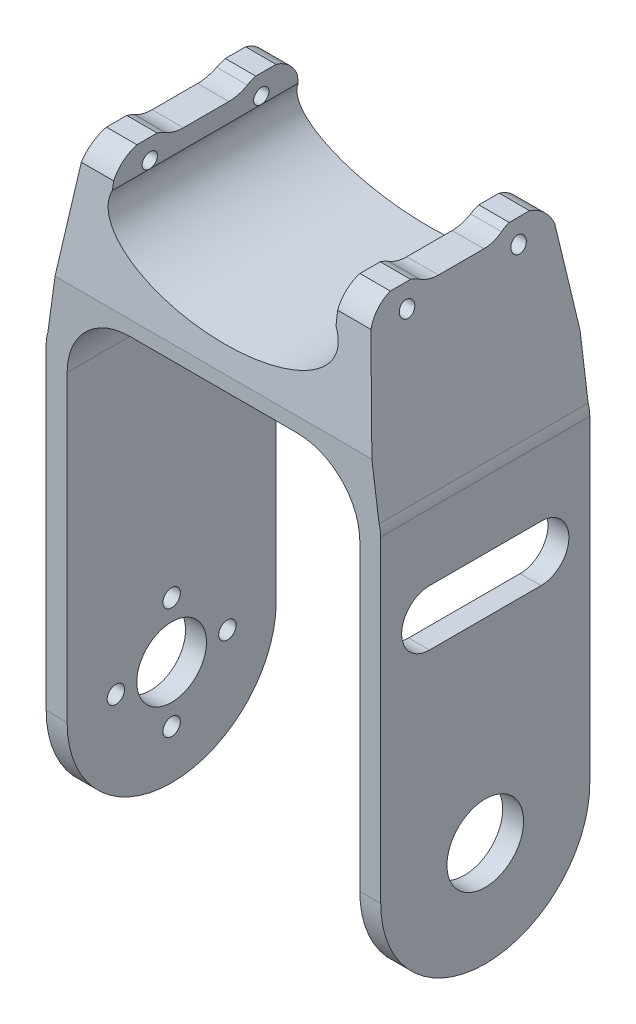
from build123d import *

# Parameters (mm, degrees)
EXTRUDE_1_DEPTH      = 30
SKETCH_3_R           = 5
CUT_EXTRUDE_5_DEPTH  = 56
CUT_EXTRUDE_12_DEPTH = 51
SKETCH_3_4_R         = 1.1
CUT_EXTRUDE_7_DEPTH  = 56
SKETCH_6_R           = 1.25
CUT_EXTRUDE_9_DEPTH  = 22
SKETCH_5_R           = 5.5
CUT_EXTRUDE_13_DEPTH = 10


with BuildPart() as part:
    # Эскиз1 → Бобышка-Вытянуть1 (new body)
    with BuildSketch(Plane.XY):
        with BuildLine():
            ThreePointArc((23.447094189, 8.182803621), (23.388195094, 8.947997617), (23.212885448, 9.69516392))
            Line((23.212885448, 9.69516392), (19.814400159, 34.41595773))
            Line((19.814400159, 34.41595773), (15.447094189, 34.41595773))
            Line((15.447094189, 34.41595773), (15.447094189, 29.601114652))
            add(Edge.make_bspline(
                [(-16.737207413, 30.306768931), (-21.154797026, 21.000420448), (-0.15838441, 20.540065316), (20.838028206, 20.079710184), (15.447094189, 29.601114652)],
                knots=[2.948852751, 2.948852751, 2.948852751, 4.755403061, 4.755403061, 6.56195337, 6.56195337, 6.56195337], degree=2, weights=[1, 0.619041122, 1, 0.619041122, 1]))
            Line((-16.737207413, 30.306768931), (-16.552905811, 34.41595773))
            Line((-16.552905811, 34.41595773), (-20.92021178, 34.41595773))
            Line((-20.92021178, 34.41595773), (-24.31869707, 9.69516392))
            ThreePointArc((-24.31869707, 9.69516392), (-24.494006715, 8.947997617), (-24.552905811, 8.182803621))
            Line((-24.552905811, 8.182803621), (-24.552905811, -52.36689041))
            Line((-24.552905811, -52.36689041), (-21.552905811, -52.36689041))
            Line((-21.552905811, -52.36689041), (-21.552905811, 5.955043958))
            Line((-21.552905811, 5.955043958), (-21.552905811, 6.111376347))
            ThreePointArc((-21.552905811, 6.111376347), (-18.916866841, 12.475337378), (-12.552905811, 15.111376347))
            Line((-12.552905811, 15.111376347), (11.447094189, 15.111376347))
            ThreePointArc((11.447094189, 15.111376347), (17.81105522, 12.475337378), (20.447094189, 6.111376347))
            Line((20.447094189, 6.111376347), (20.447094189, 5.955043958))
            Line((20.447094189, 5.955043958), (20.447094189, -52.36689041))
            Line((20.447094189, -52.36689041), (23.447094189, -52.36689041))
            Line((23.447094189, -52.36689041), (23.447094189, 8.182803621))
        make_face()
    extrude(amount=EXTRUDE_1_DEPTH)

    # Эскиз3 → Вырез-Вытянуть5 (cut)
    with BuildSketch(Plane(origin=(23.447094189, 0, 0), x_dir=(0, 0, -1), z_dir=(1, 0, 0))):
        with Locations(Location((-15, -37.36689041, 0), (0, 0, 90))):
            Circle(SKETCH_3_R)
        with BuildLine():
            ThreePointArc((-15, -52.36689041), (-25.606601718, -47.973492128), (-30, -37.36689041))
            Line((-30, -37.36689041), (-30, -52.36689041))
            Line((-30, -52.36689041), (-15, -52.36689041))
        make_face()
        with BuildLine():
            ThreePointArc((0, -37.36689041), (-4.393398282, -47.973492128), (-15, -52.36689041))
            Line((-15, -52.36689041), (0, -52.36689041))
            Line((0, -52.36689041), (0, -37.36689041))
        make_face()
    extrude(amount=-CUT_EXTRUDE_5_DEPTH, mode=Mode.SUBTRACT)

    # Эскиз2 → Вырез-Вытянуть12 (cut)
    with BuildSketch(Plane(origin=(23.447094189, 0, 0), x_dir=(0, 0, -1), z_dir=(1, 0, 0))):
        with BuildLine():
            ThreePointArc((-23.527450038, 34.63310959), (-26.347454746, 33.761980313), (-28.184823989, 31.45213897))
            Line((-28.184823989, 31.45213897), (-30.35352757, 14.45213897))
            Line((-30.35352757, 14.45213897), (-30.35352757, 34.95213897))
            Line((-30.35352757, 34.95213897), (-23.527450038, 34.63310959))
        make_face()
        with BuildLine():
            Line((-18.259623162, 33.13310959), (-15, 33.13310959))
            Line((-15, 33.13310959), (-15, 34.63310959))
            Line((-15, 34.63310959), (-23.527450038, 34.63310959))
            ThreePointArc((-23.527450038, 34.63310959), (-22.158143644, 34.441955605), (-20.8935366, 33.88310959))
            ThreePointArc((-20.8935366, 33.88310959), (-19.628929556, 33.324263575), (-18.259623162, 33.13310959))
        make_face()
        with BuildLine():
            Line((-15, 34.63310959), (-15, 33.13310959))
            Line((-15, 33.13310959), (-11.740376838, 33.13310959))
            ThreePointArc((-11.740376838, 33.13310959), (-10.371070444, 33.324263575), (-9.1064634, 33.88310959))
            ThreePointArc((-9.1064634, 33.88310959), (-7.841856356, 34.441955605), (-6.472549962, 34.63310959))
            Line((-6.472549962, 34.63310959), (-15, 34.63310959))
        make_face()
        with BuildLine():
            Line((0.509110945, 34.95310959), (-6.472549962, 34.63310959))
            ThreePointArc((-6.472549962, 34.63310959), (-3.652545254, 33.761980313), (-1.815176011, 31.45213897))
            Line((-1.815176011, 31.45213897), (0.509110945, 14.45310959))
            Line((0.509110945, 14.45310959), (0.509110945, 34.95310959))
        make_face()
    extrude(amount=-CUT_EXTRUDE_12_DEPTH, mode=Mode.SUBTRACT)

    # Эскиз3<4> → Вырез-Вытянуть7 (cut)
    with BuildSketch(Plane(origin=(23.447094189, 0, 0), x_dir=(0, 0, -1), z_dir=(1, 0, 0))):
        with Locations(Location((-23, 31.41595774, 0), (0, 0, 270))):
            Circle(SKETCH_3_4_R)
        with Locations(Location((-7, 31.41595774, 0), (0, 0, 270))):
            Circle(SKETCH_3_4_R)
    extrude(amount=-CUT_EXTRUDE_7_DEPTH, mode=Mode.SUBTRACT)

    # Эскиз6 → Вырез-Вытянуть9 (cut)
    with BuildSketch(Plane.ZY.offset(24.552905811)):
        with Locations(Location((15, -29.36689041, 0), (0, 0, 270))):
            Circle(SKETCH_6_R)
        with Locations(Location((7, -37.36689041, 0), (0, 0, 270))):
            Circle(SKETCH_6_R)
        with Locations(Location((23, -37.36689041, 0), (0, 0, 270))):
            Circle(SKETCH_6_R)
        with Locations(Location((15, -45.36689041, 0), (0, 0, 270))):
            Circle(SKETCH_6_R)
    extrude(amount=-CUT_EXTRUDE_9_DEPTH, mode=Mode.SUBTRACT)

    # Эскиз5 → Вырез-Вытянуть13 (cut)
    with BuildSketch(Plane(origin=(23.447094189, 0, 0), x_dir=(0, 0, -1), z_dir=(1, 0, 0))):
        with Locations(Location((-15, -37.36689041, 0), (0, 0, 90))):
            Circle(SKETCH_5_R)
        with BuildLine():
            Line((-15, -1.36689041), (-23, -1.36689041))
            ThreePointArc((-23, -1.36689041), (-27, -5.36689041), (-23, -9.36689041))
            Line((-23, -9.36689041), (-7, -9.36689041))
            ThreePointArc((-7, -9.36689041), (-3, -5.36689041), (-7, -1.36689041))
            Line((-7, -1.36689041), (-15, -1.36689041))
        make_face()
    extrude(amount=-CUT_EXTRUDE_13_DEPTH, mode=Mode.SUBTRACT)


solid = part.part
